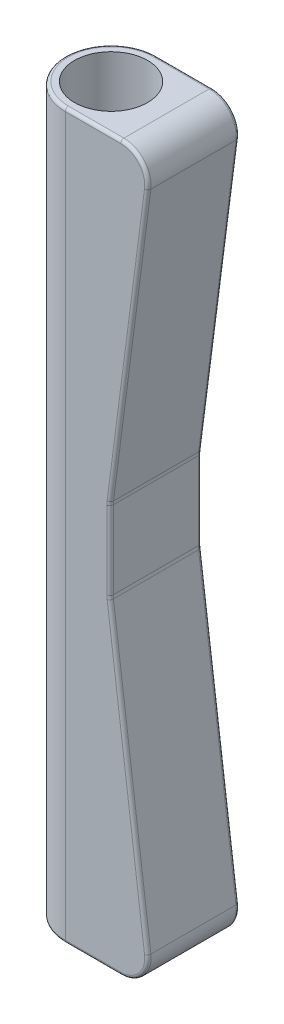
from build123d import *

# Parameters (mm, degrees)
SKETCH1_R           = 14.2875
SKETCH1_R_2         = 11.4125
BOSS_EXTRUDE1_DEPTH = 226.06
SKETCH2_W           = 28.575
SKETCH2_H           = 226.06
BOSS_EXTRUDE2_DEPTH = 12.7
BOSS_EXTRUDE3_DEPTH = 226.06
CUT_EXTRUDE1_DEPTH  = 29.575
FILLET1_R           = 8.5
FILLET2_R           = 8.5
FILLET3_R           = 1


with BuildPart() as part:
    # Sketch1 → Boss-Extrude1 (new body)
    with BuildSketch(Plane(origin=(0, 0, 0), x_dir=(1, 0, 0), z_dir=(0, 1, 0))):
        Circle(SKETCH1_R)
        Circle(SKETCH1_R_2, mode=Mode.SUBTRACT)
    extrude(amount=BOSS_EXTRUDE1_DEPTH)



with BuildPart() as body_2:
    # Sketch2 → Boss-Extrude2 (new body)
    with BuildSketch(Plane(origin=(14.2875, 0, 0), x_dir=(0, 0, -1), z_dir=(1, 0, 0))):
        with Locations((0, 113.03)):
            Rectangle(SKETCH2_W, SKETCH2_H)
    extrude(amount=BOSS_EXTRUDE2_DEPTH)


with BuildPart() as part_1:
    add(part.part)

    add(body_2.part)  # Boss-Extrude3 merges body 2
    # Sketch3 → Boss-Extrude3 (add, through all)
    with BuildSketch(Plane(origin=(0, 226.06, 0), x_dir=(1, 0, 0), z_dir=(0, 1, 0))):
        with BuildLine():
            Line((14.2875, -14.2875), (0, -14.2875))
            ThreePointArc((0, -14.2875), (14.2875, 0), (0, 14.2875))
            Line((0, 14.2875), (14.2875, 14.2875))
            Line((14.2875, 14.2875), (26.9875, 14.2875))
            Line((26.9875, 14.2875), (26.9875, -14.2875))
            Line((26.9875, -14.2875), (14.2875, -14.2875))
        make_face()
    extrude(amount=-BOSS_EXTRUDE3_DEPTH)

    # Sketch5 → Cut-Extrude1 (cut, through all)
    with BuildSketch(Plane.XY.offset(14.2875)):
        Polygon((26.9875, 226.06), (13.9875, 125.73), (13.9875, 100.33), (26.9875, 0), align=None)
    extrude(amount=-CUT_EXTRUDE1_DEPTH, mode=Mode.SUBTRACT)

    # Fillet1
    fillet1_edges = [part_1.edges().sort_by_distance(p)[0] for p in [
        (26.9875, 0, 0),
        (26.9875, 226.06, 0),
    ]]
    fillet(fillet1_edges, radius=FILLET1_R)

    # Fillet2
    fillet2_edges = [part_1.edges().sort_by_distance(p)[0] for p in [
        (13.9875, 125.73, 0),
        (13.9875, 100.33, 0),
    ]]
    fillet(fillet2_edges, radius=FILLET2_R)

    # Fillet3
    fillet3_edges = [part_1.edges().sort_by_distance(p)[0] for p in [
        (-14.2875, 0, 0),
        (8.657539107, 0, 14.2875),
        (8.657539107, 226.06, 14.2875),
        (19.901289107, 171.370804703, -14.2875),
        (8.657539107, 0, -14.2875),
        (8.657539107, 226.06, -14.2875),
        (23.69998215, 223.17097155, -14.2875),
        (23.69998215, 2.88902845, -14.2875),
        (19.901289107, 171.370804703, 14.2875),
        (23.69998215, 223.17097155, 14.2875),
        (23.69998215, 2.88902845, 14.2875),
        (19.901289107, 54.689195297, 14.2875),
        (19.901289107, 54.689195297, -14.2875),
        (13.9875, 113.03, 14.2875),
        (13.9875, 113.03, -14.2875),
        (14.005135098, 100.331137756, 14.2875),
        (14.005135098, 100.331137756, -14.2875),
        (14.005135098, 125.728862244, 14.2875),
        (14.005135098, 125.728862244, -14.2875),
        (-14.2875, 226.06, 0),
    ]]
    fillet(fillet3_edges, radius=FILLET3_R)


solid = part_1.part
